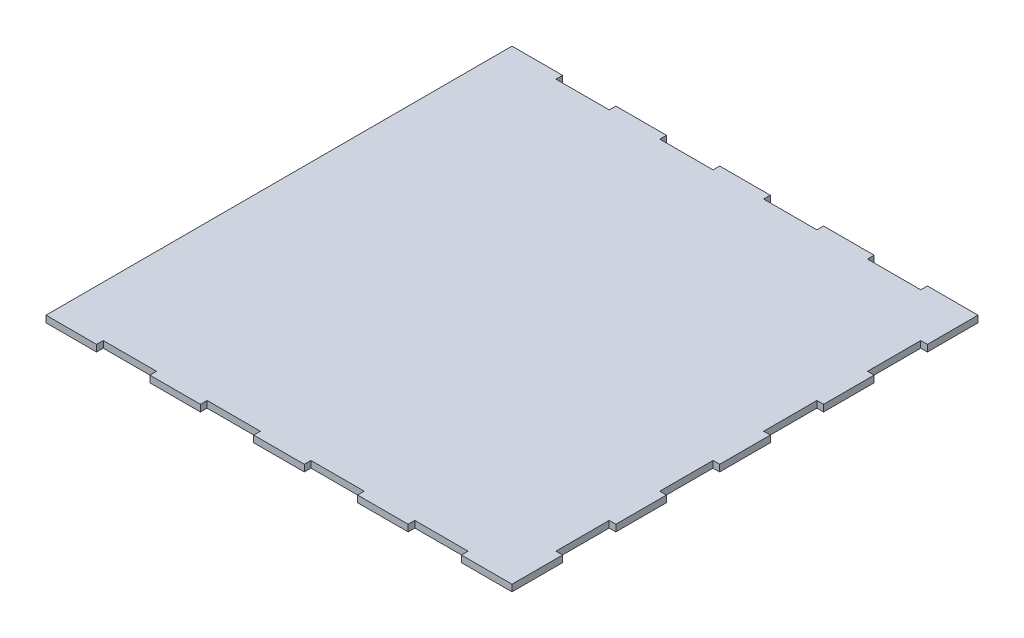
from build123d import *

# Parameters (mm, degrees)
SKIZZE1_W                       = 350
SKIZZE1_H                       = 350
GRUNDPLATTE_DEPTH               = 5
SKIZZE2_W                       = 40
SKIZZE2_H                       = 5
SCHNITT_LINEAR_AUSTRAGEN1_DEPTH = 6
KREISMUSTER1_COUNT              = 2
KREISMUSTER1_ANGLE              = 90


with BuildPart() as part:
    # Skizze1 → Grundplatte (new body)
    with BuildSketch(Plane(origin=(0, 0, 0), x_dir=(1, 0, 0), z_dir=(0, 1, 0))):
        Rectangle(SKIZZE1_W, SKIZZE1_H)
    extrude(amount=GRUNDPLATTE_DEPTH)

    # Skizze2 → Schnitt-Linear austragen1 (cut, through all)
    with BuildSketch(Plane(origin=(0, 5, 0), x_dir=(1, 0, 0), z_dir=(0, 1, 0))):
        with Locations((-117, 172.5)):
            Rectangle(SKIZZE2_W, SKIZZE2_H)
        with Locations((-39, 172.5)):
            Rectangle(SKIZZE2_W, SKIZZE2_H)
        with Locations((39, 172.5)):
            Rectangle(SKIZZE2_W, SKIZZE2_H)
        with Locations((117, 172.5)):
            Rectangle(SKIZZE2_W, SKIZZE2_H)
    schnitt_linear_austragen1 = extrude(amount=-SCHNITT_LINEAR_AUSTRAGEN1_DEPTH, mode=Mode.SUBTRACT)

    # Spiegeln1: Schnitt-Linear austragen1 across plane
    add(schnitt_linear_austragen1.mirror(Plane.XY), mode=Mode.SUBTRACT)

    # Kreismuster1: Schnitt-Linear austragen1 ×2 about axis
    kreismuster1_axis = Axis((0, 0, 0), (0, -1, 0))
    for i in range(1, KREISMUSTER1_COUNT):
        add(schnitt_linear_austragen1.rotate(kreismuster1_axis, i * KREISMUSTER1_ANGLE / (KREISMUSTER1_COUNT - 1)), mode=Mode.SUBTRACT)


solid = part.part
